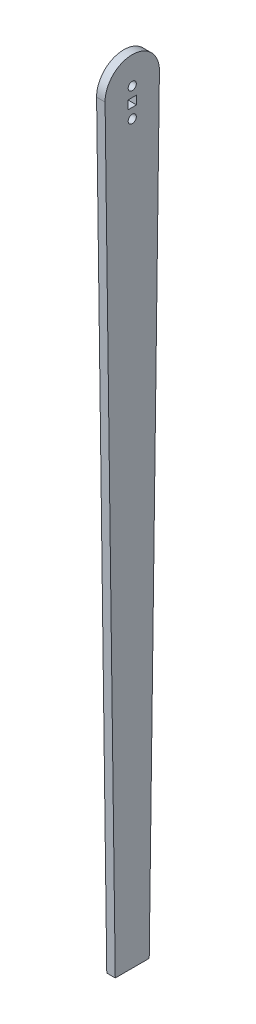
from build123d import *

# Parameters (mm, degrees)
SKETCH1_R           = 1.524
SKETCH1_W           = 3.175
SKETCH1_H           = 3.175
BOSS_EXTRUDE1_DEPTH = 3.175


with BuildPart() as part:
    # Sketch1 → Boss-Extrude1 (new body)
    with BuildSketch(Plane(origin=(0, 0, 0), x_dir=(0, 0, -1), z_dir=(1, 0, 0))):
        with BuildLine():
            Line((-6.35, -285.75), (6.35, -285.75))
            Line((6.35, -285.75), (10.159096581, -0.135486743))
            ThreePointArc((10.159096581, -0.135486743), (0, 10.16), (-10.159096581, -0.135486743))
            Line((-10.159096581, -0.135486743), (-6.35, -285.75))
        make_face()
        Circle(SKETCH1_R, mode=Mode.SUBTRACT)
        with Locations((0, -10.668)):
            Circle(SKETCH1_R, mode=Mode.SUBTRACT)
        with Locations((0, -5.334)):
            Rectangle(SKETCH1_W, SKETCH1_H, mode=Mode.SUBTRACT)
    extrude(amount=BOSS_EXTRUDE1_DEPTH)


solid = part.part
